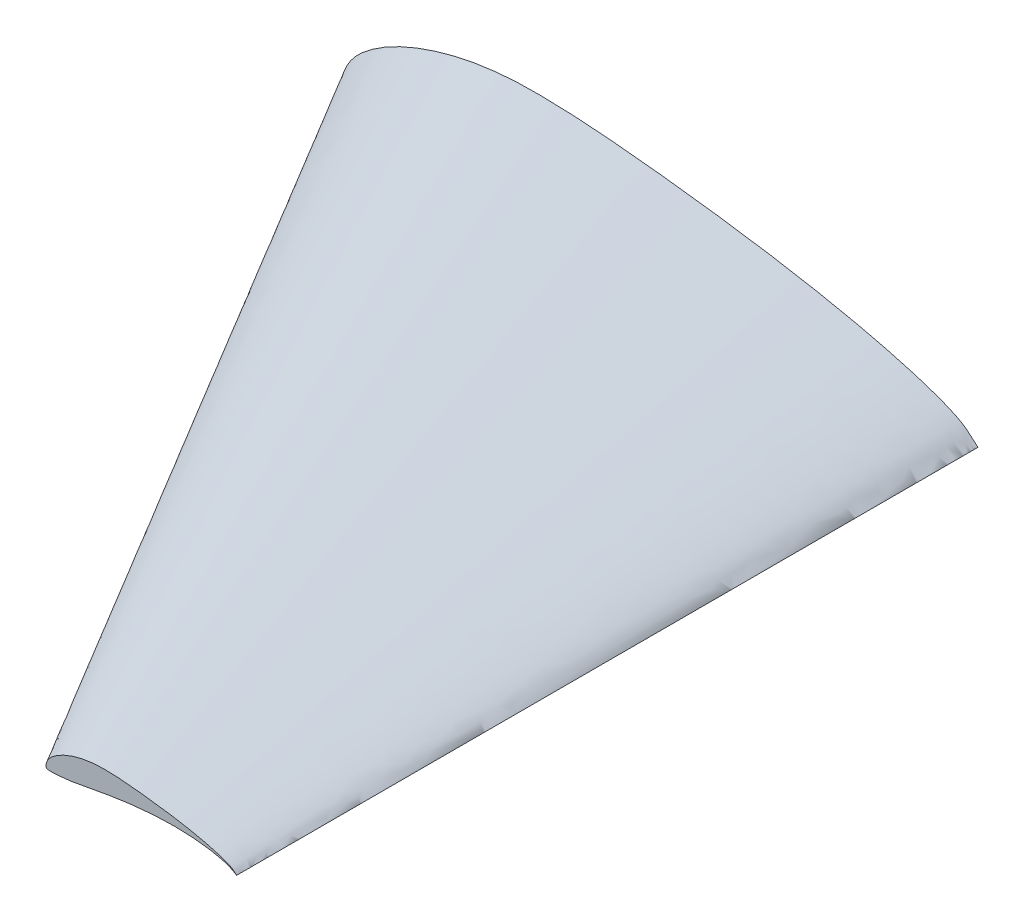
from build123d import *

# Parameters (mm, degrees)
SKETCH4_R          = 2
CUT_EXTRUDE1_DEPTH = 10
CUT_EXTRUDE2_DEPTH = 1


with BuildPart() as part:
    # Sketch3 → Loft1 section 0
    with BuildSketch(Plane.XY.offset(70)):
        with BuildLine():
            add(Edge.make_bspline(
                [(60, 0), (60.000107759, 0.00045823), (59.940935145, 0.044545857), (59.890891538, 0.093647308), (59.779774511, 0.196205337), (59.648682422, 0.305307561), (59.469359582, 0.415294301), (59.246370858, 0.521886024), (58.977168165, 0.633116991), (58.662177205, 0.747496515), (58.302798195, 0.863953961), (57.901335106, 0.982592376), (57.458471962, 1.097979924), (56.979558848, 1.219684363), (56.464360521, 1.335758178), (55.917664884, 1.451163432), (55.342255391, 1.563645721), (54.741619221, 1.672310848), (54.119503088, 1.776862794), (53.479502393, 1.875995081), (52.825753205, 1.969890082), (52.162446062, 2.057806833), (51.494385085, 2.13946315), (50.826910973, 2.215437436), (50.165549402, 2.283812601), (49.515688388, 2.343308945), (48.88189852, 2.390577682), (48.267800241, 2.423092507), (47.676809978, 2.437133923), (47.111955291, 2.435639306), (46.574289852, 2.407982369), (46.063605386, 2.351936832), (45.577823009, 2.272687612), (45.116825477, 2.170020947), (44.681086398, 2.04962996), (44.272449438, 1.913646961), (43.892652493, 1.765251918), (43.544055665, 1.605239875), (43.227776887, 1.436859538), (42.94553682, 1.262025717), (42.699105421, 1.083107561), (42.488584367, 0.903897458), (42.317026583, 0.722439194), (42.185248322, 0.540304202), (42.08790704, 0.363111111), (42.025521579, 0.194874666), (41.995794905, 0.039592478), (42.001532957, -0.091739447), (42.035344873, -0.212191985), (42.16102918, -0.271985507), (42.33001338, -0.28037435), (42.561183137, -0.288504849), (42.85189542, -0.275968725), (43.198864607, -0.252931149), (43.598229294, -0.216029949), (44.045902873, -0.166101037), (44.539702369, -0.102073031), (45.07938647, -0.012584366), (45.667582852, 0.09963297), (46.307232102, 0.221761241), (46.995207664, 0.350711186), (47.72718833, 0.481130505), (48.497798407, 0.608124713), (49.301059449, 0.727453141), (50.130048988, 0.834738394), (50.977312155, 0.926856584), (51.834845451, 0.99967222), (52.694043317, 1.051289527), (53.545929342, 1.07966642), (54.381262057, 1.083250625), (55.190722018, 1.061798612), (55.965040428, 1.015812577), (56.694906217, 0.945885863), (57.371629898, 0.8547026), (57.986400744, 0.744908581), (58.532010839, 0.620180946), (58.99840484, 0.486716819), (59.380100231, 0.344272382), (59.652430067, 0.213917485), (59.853211585, 0.093386968), (59.93034321, 0.046743647), (59.99989005, -0.000467545), (60, 0)],
                knots=[0, 0, 0, 0, 0.000979678, 0.003648865, 0.007483504, 0.012095286, 0.017525603, 0.024051797, 0.031783073, 0.040677857, 0.050710337, 0.061833274, 0.073978206, 0.087117514, 0.1011444, 0.115989999, 0.131569795, 0.147787764, 0.164550314, 0.181757305, 0.199311377, 0.217094507, 0.234989676, 0.252856344, 0.270540067, 0.287886265, 0.304772936, 0.321100929, 0.336805584, 0.351799565, 0.366030606, 0.379615227, 0.392652524, 0.405169929, 0.417171498, 0.428603104, 0.439418554, 0.449596189, 0.459101689, 0.467907493, 0.475987922, 0.483308596, 0.48987414, 0.495802886, 0.501149052, 0.505902717, 0.510046415, 0.51357896, 0.516446578, 0.519349706, 0.523823011, 0.529973455, 0.537715321, 0.546967517, 0.557637048, 0.56962017, 0.582803823, 0.59724667, 0.613134757, 0.630443334, 0.64905587, 0.668822018, 0.68959474, 0.711189442, 0.733426497, 0.756093941, 0.778988394, 0.80188954, 0.824566471, 0.846792174, 0.868338195, 0.888978083, 0.908491945, 0.926658715, 0.943286152, 0.95816918, 0.971135801, 0.98195561, 0.990251784, 0.995852562, 0.999000405, 1, 1, 1, 1], degree=3))
        make_face()
    # Sketch2 → Loft1 section 1
    with BuildSketch(Plane.XY):
        with BuildLine():
            add(Edge.make_bspline(
                [(60, 0), (60.000359197, 0.001527432), (59.80311715, 0.148486191), (59.636305128, 0.312157693), (59.265915035, 0.654017791), (58.828941408, 1.01769187), (58.231198607, 1.384314338), (57.487902859, 1.739620081), (56.590560551, 2.110389969), (55.540590684, 2.491655052), (54.342660651, 2.879846537), (53.004450354, 3.275307919), (51.528239873, 3.659933081), (49.931862826, 4.065614543), (48.21453507, 4.45252726), (46.392216281, 4.837211439), (44.474184637, 5.212152404), (42.47206407, 5.574369492), (40.398343628, 5.92287598), (38.265007978, 6.253316937), (36.085844017, 6.566300275), (33.874820207, 6.859356111), (31.647950283, 7.131543832), (29.423036576, 7.384791452), (27.218498007, 7.612708672), (25.052294626, 7.811029816), (22.939661735, 7.968592274), (20.892667469, 8.076975023), (18.922699926, 8.123779744), (17.039850969, 8.118797688), (15.247632842, 8.026607898), (13.545351286, 7.839789441), (11.926076695, 7.575625373), (10.389418256, 7.233403155), (8.93695466, 6.832099867), (7.574831461, 6.378823205), (6.308841643, 5.884173059), (5.146852216, 5.350799583), (4.092589623, 4.789531794), (3.151789401, 4.20675239), (2.330351404, 3.610358538), (1.628614556, 3.012991527), (1.056755276, 2.408130647), (0.617494407, 1.801014007), (0.293023466, 1.210370369), (0.085071932, 0.649582219), (-0.014016985, 0.131974926), (0.005109858, -0.305798158), (0.117816245, -0.707306616), (0.536763933, -0.906618356), (1.100044602, -0.934581165), (1.870610456, -0.96168283), (2.8396514, -0.91989575), (3.996215358, -0.843103831), (5.32743098, -0.720099828), (6.819676242, -0.553670124), (8.465674563, -0.340243438), (10.264621567, -0.041947886), (12.225276175, 0.332109901), (14.357440339, 0.739204138), (16.650692214, 1.169037288), (19.090627767, 1.60376835), (21.659328024, 2.027082377), (24.336864829, 2.424843805), (27.100163295, 2.782461315), (29.924373851, 3.089521947), (32.78281817, 3.332240734), (35.646811058, 3.504298425), (38.486431141, 3.598888068), (41.270873525, 3.610835418), (43.969073393, 3.539328707), (46.550134759, 3.386041923), (48.983020725, 3.152952876), (51.238766327, 2.849008665), (53.28800248, 2.483028604), (55.106702797, 2.06726982), (56.661349467, 1.622389398), (57.933667436, 1.147574605), (58.841433556, 0.713058282), (59.510705283, 0.311289894), (59.767810701, 0.155812155), (59.999633501, -0.001558484), (60, 0)],
                knots=[0, 0, 0, 0, 0.000979678, 0.003648865, 0.007483504, 0.012095286, 0.017525603, 0.024051797, 0.031783073, 0.040677857, 0.050710337, 0.061833274, 0.073978206, 0.087117514, 0.1011444, 0.115989999, 0.131569795, 0.147787764, 0.164550314, 0.181757305, 0.199311377, 0.217094507, 0.234989676, 0.252856344, 0.270540067, 0.287886265, 0.304772936, 0.321100929, 0.336805584, 0.351799565, 0.366030606, 0.379615227, 0.392652524, 0.405169929, 0.417171498, 0.428603104, 0.439418554, 0.449596189, 0.459101689, 0.467907493, 0.475987922, 0.483308596, 0.48987414, 0.495802886, 0.501149052, 0.505902717, 0.510046415, 0.51357896, 0.516446578, 0.519349706, 0.523823011, 0.529973455, 0.537715321, 0.546967517, 0.557637048, 0.56962017, 0.582803823, 0.59724667, 0.613134757, 0.630443334, 0.64905587, 0.668822018, 0.68959474, 0.711189442, 0.733426497, 0.756093941, 0.778988394, 0.80188954, 0.824566471, 0.846792174, 0.868338195, 0.888978083, 0.908491945, 0.926658715, 0.943286152, 0.95816918, 0.971135801, 0.98195561, 0.990251784, 0.995852562, 0.999000405, 1, 1, 1, 1], degree=3))
        make_face()
    loft()

    # Sketch4 → Cut-Extrude1 (cut)
    with BuildSketch(Plane(origin=(0, 0, 0), x_dir=(-1, 0, 0), z_dir=(0, 0, -1))):
        with Locations((-23.51, 5)):
            Circle(SKETCH4_R)
    extrude(amount=-CUT_EXTRUDE1_DEPTH, mode=Mode.SUBTRACT)

    # Sketch4_3 → Cut-Extrude2 (cut)
    with BuildSketch(Plane(origin=(0, 0, 0), x_dir=(-1, 0, 0), z_dir=(0, 0, -1))):
        with BuildLine():
            Line((-40.02, 5.75), (-27.02, 5.75))
            ThreePointArc((-27.02, 5.75), (-26.27, 5), (-27.02, 4.25))
            Line((-27.02, 4.25), (-40.02, 4.25))
            ThreePointArc((-40.02, 4.25), (-40.77, 5), (-40.02, 5.75))
        make_face()
        with BuildLine():
            Line((-7, 5.75), (-20, 5.75))
            ThreePointArc((-20, 5.75), (-20.75, 5), (-20, 4.25))
            Line((-20, 4.25), (-7, 4.25))
            ThreePointArc((-7, 4.25), (-6.25, 5), (-7, 5.75))
        make_face()
    extrude(amount=-CUT_EXTRUDE2_DEPTH, mode=Mode.SUBTRACT)


solid = part.part
